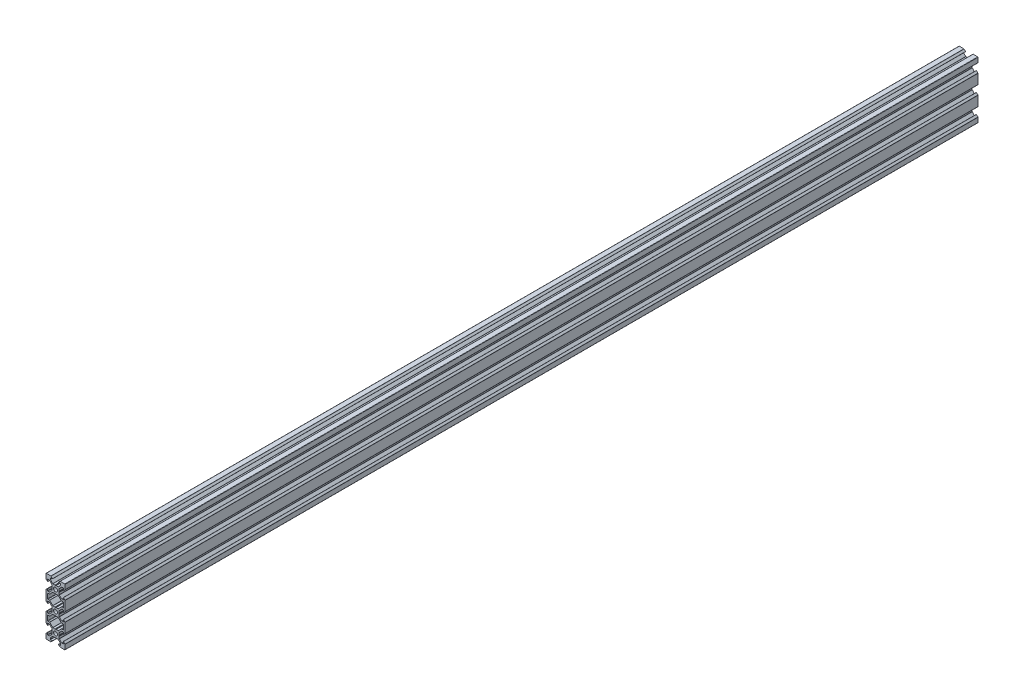
from build123d import *

# Parameters (mm, degrees)
BOSS_EXTRU_1_DEPTH = 960


with BuildPart() as part:
    # Esquisse1 → Boss.-Extru.1 (new body)
    with BuildSketch(Plane.XY):
        with BuildLine():
            Line((6.114160649, 19.573320158), (6.414160649, 20.0929354))
            Line((6.414160649, 20.0929354), (6.414160649, 22.289056089))
            ThreePointArc((6.414160649, 22.289056089), (6.43699679, 22.403861119), (6.502028615, 22.501188124))
            Line((6.502028615, 22.501188124), (8.985632512, 24.984792021))
            ThreePointArc((8.985632512, 24.984792021), (9.082959517, 25.049823846), (9.197764546, 25.072659986))
            Line((9.197764546, 25.072659986), (10.413500478, 25.072659986))
            ThreePointArc((10.413500478, 25.072659986), (10.625632512, 24.984792021), (10.713500478, 24.772659986))
            Line((10.713500478, 24.772659986), (10.713500478, 22.773320158))
            ThreePointArc((10.713500478, 22.773320158), (10.775232134, 22.680932205), (10.884211156, 22.70260948))
            Line((10.884211156, 22.70260948), (12.425632512, 24.244030836))
            ThreePointArc((12.425632512, 24.244030836), (12.490664337, 24.341357841), (12.513500478, 24.456162871))
            Line((12.513500478, 24.456162871), (12.513500478, 29.273320158))
            ThreePointArc((12.513500478, 29.273320158), (12.425632512, 29.485452192), (12.213500478, 29.573320158))
            Line((12.213500478, 29.573320158), (7.39634319, 29.573320158))
            ThreePointArc((7.39634319, 29.573320158), (7.28153816, 29.550484018), (7.184211156, 29.485452192))
            Line((7.184211156, 29.485452192), (5.642789799, 27.944030836))
            ThreePointArc((5.642789799, 27.944030836), (5.621112524, 27.835051815), (5.713500478, 27.773320158))
            Line((5.713500478, 27.773320158), (7.712840306, 27.773320158))
            ThreePointArc((7.712840306, 27.773320158), (7.92497234, 27.685452192), (8.012840306, 27.473320158))
            Line((8.012840306, 27.473320158), (8.012840306, 26.257584227))
            ThreePointArc((8.012840306, 26.257584227), (7.990004166, 26.142779197), (7.92497234, 26.045452192))
            Line((7.92497234, 26.045452192), (5.441368443, 23.561848296))
            ThreePointArc((5.441368443, 23.561848296), (5.344041439, 23.49681647), (5.229236409, 23.47398033))
            Line((5.229236409, 23.47398033), (3.03311572, 23.47398033))
            Line((3.03311572, 23.47398033), (2.513500478, 23.17398033))
            Line((2.513500478, 23.17398033), (1.993885235, 23.47398033))
            Line((1.993885235, 23.47398033), (-0.202235454, 23.47398033))
            ThreePointArc((-0.202235454, 23.47398033), (-0.317040483, 23.49681647), (-0.414367488, 23.561848296))
            Line((-0.414367488, 23.561848296), (-2.897971385, 26.045452192))
            ThreePointArc((-2.897971385, 26.045452192), (-2.96300321, 26.142779197), (-2.985839351, 26.257584227))
            Line((-2.985839351, 26.257584227), (-2.985839351, 27.473320158))
            ThreePointArc((-2.985839351, 27.473320158), (-2.897971385, 27.685452192), (-2.685839351, 27.773320158))
            Line((-2.685839351, 27.773320158), (-0.686499522, 27.773320158))
            ThreePointArc((-0.686499522, 27.773320158), (-0.594111569, 27.835051815), (-0.615788844, 27.944030836))
            Line((-0.615788844, 27.944030836), (-2.157210201, 29.485452192))
            ThreePointArc((-2.157210201, 29.485452192), (-2.254537205, 29.550484018), (-2.369342235, 29.573320158))
            Line((-2.369342235, 29.573320158), (-7.186499522, 29.573320158))
            ThreePointArc((-7.186499522, 29.573320158), (-7.398631557, 29.485452192), (-7.486499522, 29.273320158))
            Line((-7.486499522, 29.273320158), (-7.486499522, 24.456162871))
            ThreePointArc((-7.486499522, 24.456162871), (-7.463663382, 24.341357841), (-7.398631557, 24.244030836))
            Line((-7.398631557, 24.244030836), (-5.857210201, 22.70260948))
            ThreePointArc((-5.857210201, 22.70260948), (-5.748231179, 22.680932205), (-5.686499522, 22.773320158))
            Line((-5.686499522, 22.773320158), (-5.686499522, 24.772659986))
            ThreePointArc((-5.686499522, 24.772659986), (-5.598631557, 24.984792021), (-5.386499522, 25.072659986))
            Line((-5.386499522, 25.072659986), (-4.170763591, 25.072659986))
            ThreePointArc((-4.170763591, 25.072659986), (-4.055958561, 25.049823846), (-3.958631557, 24.984792021))
            Line((-3.958631557, 24.984792021), (-1.47502766, 22.501188124))
            ThreePointArc((-1.47502766, 22.501188124), (-1.409995834, 22.403861119), (-1.387159694, 22.289056089))
            Line((-1.387159694, 22.289056089), (-1.387159694, 20.0929354))
            Line((-1.387159694, 20.0929354), (-1.087159694, 19.573320158))
            Line((-1.087159694, 19.573320158), (-1.387159694, 19.053704916))
            Line((-1.387159694, 19.053704916), (-1.387159694, 16.857584227))
            ThreePointArc((-1.387159694, 16.857584227), (-1.409995834, 16.742779197), (-1.47502766, 16.645452192))
            Line((-1.47502766, 16.645452192), (-3.958631557, 14.161848296))
            ThreePointArc((-3.958631557, 14.161848296), (-4.055958561, 14.09681647), (-4.170763591, 14.07398033))
            Line((-4.170763591, 14.07398033), (-5.386499522, 14.07398033))
            ThreePointArc((-5.386499522, 14.07398033), (-5.598631557, 14.161848296), (-5.686499522, 14.37398033))
            Line((-5.686499522, 14.37398033), (-5.686499522, 16.373320158))
            ThreePointArc((-5.686499522, 16.373320158), (-5.748231179, 16.465708111), (-5.857210201, 16.444030836))
            Line((-5.857210201, 16.444030836), (-7.398631557, 14.90260948))
            ThreePointArc((-7.398631557, 14.90260948), (-7.463663382, 14.805282475), (-7.486499522, 14.690477446))
            Line((-7.486499522, 14.690477446), (-7.486499522, 9.573320158))
            Line((-7.486499522, 9.573320158), (-7.486499522, 4.456162871))
            ThreePointArc((-7.486499522, 4.456162871), (-7.463663382, 4.341357841), (-7.398631557, 4.244030836))
            Line((-7.398631557, 4.244030836), (-5.857210201, 2.70260948))
            ThreePointArc((-5.857210201, 2.70260948), (-5.748231179, 2.680932205), (-5.686499522, 2.773320158))
            Line((-5.686499522, 2.773320158), (-5.686499522, 4.772659986))
            ThreePointArc((-5.686499522, 4.772659986), (-5.598631557, 4.984792021), (-5.386499522, 5.072659986))
            Line((-5.386499522, 5.072659986), (-4.170763591, 5.072659986))
            ThreePointArc((-4.170763591, 5.072659986), (-4.055958561, 5.049823846), (-3.958631557, 4.984792021))
            Line((-3.958631557, 4.984792021), (-1.47502766, 2.501188124))
            ThreePointArc((-1.47502766, 2.501188124), (-1.409995834, 2.403861119), (-1.387159694, 2.289056089))
            Line((-1.387159694, 2.289056089), (-1.387159694, 0.0929354))
            Line((-1.387159694, 0.0929354), (-1.087159694, -0.426679842))
            Line((-1.087159694, -0.426679842), (-1.387159694, -0.946295084))
            Line((-1.387159694, -0.946295084), (-1.387159694, -3.142415773))
            ThreePointArc((-1.387159694, -3.142415773), (-1.409995834, -3.257220803), (-1.47502766, -3.354547808))
            Line((-1.47502766, -3.354547808), (-3.958631557, -5.838151704))
            ThreePointArc((-3.958631557, -5.838151704), (-4.055958561, -5.90318353), (-4.170763591, -5.92601967))
            Line((-4.170763591, -5.92601967), (-5.386499522, -5.92601967))
            ThreePointArc((-5.386499522, -5.92601967), (-5.598631557, -5.838151704), (-5.686499522, -5.62601967))
            Line((-5.686499522, -5.62601967), (-5.686499522, -3.626679842))
            ThreePointArc((-5.686499522, -3.626679842), (-5.748231179, -3.534291889), (-5.857210201, -3.555969164))
            Line((-5.857210201, -3.555969164), (-7.398631557, -5.09739052))
            ThreePointArc((-7.398631557, -5.09739052), (-7.463663382, -5.194717525), (-7.486499522, -5.309522554))
            Line((-7.486499522, -5.309522554), (-7.486499522, -10.426679842))
            Line((-7.486499522, -10.426679842), (-7.486499522, -15.543837129))
            ThreePointArc((-7.486499522, -15.543837129), (-7.463663382, -15.658642159), (-7.398631557, -15.755969164))
            Line((-7.398631557, -15.755969164), (-5.857210201, -17.29739052))
            ThreePointArc((-5.857210201, -17.29739052), (-5.748231179, -17.319067795), (-5.686499522, -17.226679842))
            Line((-5.686499522, -17.226679842), (-5.686499522, -15.227340014))
            ThreePointArc((-5.686499522, -15.227340014), (-5.598631557, -15.015207979), (-5.386499522, -14.927340014))
            Line((-5.386499522, -14.927340014), (-4.170763591, -14.927340014))
            ThreePointArc((-4.170763591, -14.927340014), (-4.055958561, -14.950176154), (-3.958631557, -15.015207979))
            Line((-3.958631557, -15.015207979), (-1.47502766, -17.498811876))
            ThreePointArc((-1.47502766, -17.498811876), (-1.409995834, -17.596138881), (-1.387159694, -17.710943911))
            Line((-1.387159694, -17.710943911), (-1.387159694, -19.9070646))
            Line((-1.387159694, -19.9070646), (-1.087159694, -20.426679842))
            Line((-1.087159694, -20.426679842), (-1.387159694, -20.946295084))
            Line((-1.387159694, -20.946295084), (-1.387159694, -23.142415773))
            ThreePointArc((-1.387159694, -23.142415773), (-1.409995834, -23.257220803), (-1.47502766, -23.354547808))
            Line((-1.47502766, -23.354547808), (-3.958631557, -25.838151704))
            ThreePointArc((-3.958631557, -25.838151704), (-4.055958561, -25.90318353), (-4.170763591, -25.92601967))
            Line((-4.170763591, -25.92601967), (-5.386499522, -25.92601967))
            ThreePointArc((-5.386499522, -25.92601967), (-5.598631557, -25.838151704), (-5.686499522, -25.62601967))
            Line((-5.686499522, -25.62601967), (-5.686499522, -23.626679842))
            ThreePointArc((-5.686499522, -23.626679842), (-5.748231179, -23.534291889), (-5.857210201, -23.555969164))
            Line((-5.857210201, -23.555969164), (-7.398631557, -25.09739052))
            ThreePointArc((-7.398631557, -25.09739052), (-7.463663382, -25.194717525), (-7.486499522, -25.309522554))
            Line((-7.486499522, -25.309522554), (-7.486499522, -30.126679842))
            ThreePointArc((-7.486499522, -30.126679842), (-7.398631557, -30.338811876), (-7.186499522, -30.426679842))
            Line((-7.186499522, -30.426679842), (-2.369342235, -30.426679842))
            ThreePointArc((-2.369342235, -30.426679842), (-2.254537205, -30.403843702), (-2.157210201, -30.338811876))
            Line((-2.157210201, -30.338811876), (-0.615788844, -28.79739052))
            ThreePointArc((-0.615788844, -28.79739052), (-0.594111569, -28.688411499), (-0.686499522, -28.626679842))
            Line((-0.686499522, -28.626679842), (-2.685839351, -28.626679842))
            ThreePointArc((-2.685839351, -28.626679842), (-2.897971385, -28.538811876), (-2.985839351, -28.326679842))
            Line((-2.985839351, -28.326679842), (-2.985839351, -27.110943911))
            ThreePointArc((-2.985839351, -27.110943911), (-2.96300321, -26.996138881), (-2.897971385, -26.898811876))
            Line((-2.897971385, -26.898811876), (-0.414367488, -24.415207979))
            ThreePointArc((-0.414367488, -24.415207979), (-0.317040483, -24.350176154), (-0.202235454, -24.327340014))
            Line((-0.202235454, -24.327340014), (1.993885235, -24.327340014))
            Line((1.993885235, -24.327340014), (2.513500478, -24.027340014))
            Line((2.513500478, -24.027340014), (3.03311572, -24.327340014))
            Line((3.03311572, -24.327340014), (5.229236409, -24.327340014))
            ThreePointArc((5.229236409, -24.327340014), (5.344041439, -24.350176154), (5.441368443, -24.415207979))
            Line((5.441368443, -24.415207979), (7.92497234, -26.898811876))
            ThreePointArc((7.92497234, -26.898811876), (7.990004166, -26.996138881), (8.012840306, -27.110943911))
            Line((8.012840306, -27.110943911), (8.012840306, -28.326679842))
            ThreePointArc((8.012840306, -28.326679842), (7.92497234, -28.538811876), (7.712840306, -28.626679842))
            Line((7.712840306, -28.626679842), (5.713500478, -28.626679842))
            ThreePointArc((5.713500478, -28.626679842), (5.621112524, -28.688411499), (5.642789799, -28.79739052))
            Line((5.642789799, -28.79739052), (7.184211156, -30.338811876))
            ThreePointArc((7.184211156, -30.338811876), (7.28153816, -30.403843702), (7.39634319, -30.426679842))
            Line((7.39634319, -30.426679842), (12.213500478, -30.426679842))
            ThreePointArc((12.213500478, -30.426679842), (12.425632512, -30.338811876), (12.513500478, -30.126679842))
            Line((12.513500478, -30.126679842), (12.513500478, -25.309522554))
            ThreePointArc((12.513500478, -25.309522554), (12.490664337, -25.194717525), (12.425632512, -25.09739052))
            Line((12.425632512, -25.09739052), (10.884211156, -23.555969164))
            ThreePointArc((10.884211156, -23.555969164), (10.775232134, -23.534291889), (10.713500478, -23.626679842))
            Line((10.713500478, -23.626679842), (10.713500478, -25.62601967))
            ThreePointArc((10.713500478, -25.62601967), (10.625632512, -25.838151704), (10.413500478, -25.92601967))
            Line((10.413500478, -25.92601967), (9.197764546, -25.92601967))
            ThreePointArc((9.197764546, -25.92601967), (9.082959517, -25.90318353), (8.985632512, -25.838151704))
            Line((8.985632512, -25.838151704), (6.502028615, -23.354547808))
            ThreePointArc((6.502028615, -23.354547808), (6.43699679, -23.257220803), (6.414160649, -23.142415773))
            Line((6.414160649, -23.142415773), (6.414160649, -20.946295084))
            Line((6.414160649, -20.946295084), (6.114160649, -20.426679842))
            Line((6.114160649, -20.426679842), (6.414160649, -19.9070646))
            Line((6.414160649, -19.9070646), (6.414160649, -17.710943911))
            ThreePointArc((6.414160649, -17.710943911), (6.43699679, -17.596138881), (6.502028615, -17.498811876))
            Line((6.502028615, -17.498811876), (8.985632512, -15.015207979))
            ThreePointArc((8.985632512, -15.015207979), (9.082959517, -14.950176154), (9.197764546, -14.927340014))
            Line((9.197764546, -14.927340014), (10.413500478, -14.927340014))
            ThreePointArc((10.413500478, -14.927340014), (10.625632512, -15.015207979), (10.713500478, -15.227340014))
            Line((10.713500478, -15.227340014), (10.713500478, -17.226679842))
            ThreePointArc((10.713500478, -17.226679842), (10.775232134, -17.319067795), (10.884211156, -17.29739052))
            Line((10.884211156, -17.29739052), (12.425632512, -15.755969164))
            ThreePointArc((12.425632512, -15.755969164), (12.490664337, -15.658642159), (12.513500478, -15.543837129))
            Line((12.513500478, -15.543837129), (12.513500478, -10.426679842))
            Line((12.513500478, -10.426679842), (12.513500478, -5.309522554))
            ThreePointArc((12.513500478, -5.309522554), (12.490664337, -5.194717525), (12.425632512, -5.09739052))
            Line((12.425632512, -5.09739052), (10.884211156, -3.555969164))
            ThreePointArc((10.884211156, -3.555969164), (10.775232134, -3.534291889), (10.713500478, -3.626679842))
            Line((10.713500478, -3.626679842), (10.713500478, -5.62601967))
            ThreePointArc((10.713500478, -5.62601967), (10.625632512, -5.838151704), (10.413500478, -5.92601967))
            Line((10.413500478, -5.92601967), (9.197764546, -5.92601967))
            ThreePointArc((9.197764546, -5.92601967), (9.082959517, -5.90318353), (8.985632512, -5.838151704))
            Line((8.985632512, -5.838151704), (6.502028615, -3.354547808))
            ThreePointArc((6.502028615, -3.354547808), (6.43699679, -3.257220803), (6.414160649, -3.142415773))
            Line((6.414160649, -3.142415773), (6.414160649, -0.946295084))
            Line((6.414160649, -0.946295084), (6.114160649, -0.426679842))
            Line((6.114160649, -0.426679842), (6.414160649, 0.0929354))
            Line((6.414160649, 0.0929354), (6.414160649, 2.289056089))
            ThreePointArc((6.414160649, 2.289056089), (6.43699679, 2.403861119), (6.502028615, 2.501188124))
            Line((6.502028615, 2.501188124), (8.985632512, 4.984792021))
            ThreePointArc((8.985632512, 4.984792021), (9.082959517, 5.049823846), (9.197764546, 5.072659986))
            Line((9.197764546, 5.072659986), (10.413500478, 5.072659986))
            ThreePointArc((10.413500478, 5.072659986), (10.625632512, 4.984792021), (10.713500478, 4.772659986))
            Line((10.713500478, 4.772659986), (10.713500478, 2.773320158))
            ThreePointArc((10.713500478, 2.773320158), (10.775232134, 2.680932205), (10.884211156, 2.70260948))
            Line((10.884211156, 2.70260948), (12.425632512, 4.244030836))
            ThreePointArc((12.425632512, 4.244030836), (12.490664337, 4.341357841), (12.513500478, 4.456162871))
            Line((12.513500478, 4.456162871), (12.513500478, 9.573320158))
            Line((12.513500478, 9.573320158), (12.513500478, 14.690477446))
            ThreePointArc((12.513500478, 14.690477446), (12.490664337, 14.805282475), (12.425632512, 14.90260948))
            Line((12.425632512, 14.90260948), (10.884211156, 16.444030836))
            ThreePointArc((10.884211156, 16.444030836), (10.775232134, 16.465708111), (10.713500478, 16.373320158))
            Line((10.713500478, 16.373320158), (10.713500478, 14.37398033))
            ThreePointArc((10.713500478, 14.37398033), (10.625632512, 14.161848296), (10.413500478, 14.07398033))
            Line((10.413500478, 14.07398033), (9.197764546, 14.07398033))
            ThreePointArc((9.197764546, 14.07398033), (9.082959517, 14.09681647), (8.985632512, 14.161848296))
            Line((8.985632512, 14.161848296), (6.502028615, 16.645452192))
            ThreePointArc((6.502028615, 16.645452192), (6.43699679, 16.742779197), (6.414160649, 16.857584227))
            Line((6.414160649, 16.857584227), (6.414160649, 19.053704916))
            Line((6.414160649, 19.053704916), (6.114160649, 19.573320158))
        make_face()
        with BuildLine():
            Line((10.413500478, -7.687340014), (8.837764546, -7.687340014))
            ThreePointArc((8.837764546, -7.687340014), (8.722959517, -7.664503873), (8.625632512, -7.599472048))
            Line((8.625632512, -7.599472048), (5.441368443, -4.415207979))
            ThreePointArc((5.441368443, -4.415207979), (5.344041439, -4.350176154), (5.229236409, -4.327340014))
            Line((5.229236409, -4.327340014), (3.03311572, -4.327340014))
            Line((3.03311572, -4.327340014), (2.513500478, -4.027340014))
            Line((2.513500478, -4.027340014), (1.993885235, -4.327340014))
            Line((1.993885235, -4.327340014), (-0.202235454, -4.327340014))
            ThreePointArc((-0.202235454, -4.327340014), (-0.317040483, -4.350176154), (-0.414367488, -4.415207979))
            Line((-0.414367488, -4.415207979), (-3.598631557, -7.599472048))
            ThreePointArc((-3.598631557, -7.599472048), (-3.695958561, -7.664503873), (-3.810763591, -7.687340014))
            Line((-3.810763591, -7.687340014), (-5.386499522, -7.687340014))
            ThreePointArc((-5.386499522, -7.687340014), (-5.598631557, -7.775207979), (-5.686499522, -7.987340014))
            Line((-5.686499522, -7.987340014), (-5.686499522, -10.426679842))
            Line((-5.686499522, -10.426679842), (-5.686499522, -12.86601967))
            ThreePointArc((-5.686499522, -12.86601967), (-5.598631557, -13.078151704), (-5.386499522, -13.16601967))
            Line((-5.386499522, -13.16601967), (-3.810763591, -13.16601967))
            ThreePointArc((-3.810763591, -13.16601967), (-3.695958561, -13.18885581), (-3.598631557, -13.253887636))
            Line((-3.598631557, -13.253887636), (-0.414367488, -16.438151704))
            ThreePointArc((-0.414367488, -16.438151704), (-0.317040483, -16.50318353), (-0.202235454, -16.52601967))
            Line((-0.202235454, -16.52601967), (1.993885235, -16.52601967))
            Line((1.993885235, -16.52601967), (2.513500478, -16.82601967))
            Line((2.513500478, -16.82601967), (3.03311572, -16.52601967))
            Line((3.03311572, -16.52601967), (5.229236409, -16.52601967))
            ThreePointArc((5.229236409, -16.52601967), (5.344041439, -16.50318353), (5.441368443, -16.438151704))
            Line((5.441368443, -16.438151704), (8.625632512, -13.253887636))
            ThreePointArc((8.625632512, -13.253887636), (8.722959517, -13.18885581), (8.837764546, -13.16601967))
            Line((8.837764546, -13.16601967), (10.413500478, -13.16601967))
            ThreePointArc((10.413500478, -13.16601967), (10.625632512, -13.078151704), (10.713500478, -12.86601967))
            Line((10.713500478, -12.86601967), (10.713500478, -10.426679842))
            Line((10.713500478, -10.426679842), (10.713500478, -7.987340014))
            ThreePointArc((10.713500478, -7.987340014), (10.625632512, -7.775207979), (10.413500478, -7.687340014))
        make_face(mode=Mode.SUBTRACT)
        with BuildLine():
            Line((10.413500478, 12.312659986), (8.837764546, 12.312659986))
            ThreePointArc((8.837764546, 12.312659986), (8.722959517, 12.335496127), (8.625632512, 12.400527952))
            Line((8.625632512, 12.400527952), (5.441368443, 15.584792021))
            ThreePointArc((5.441368443, 15.584792021), (5.344041439, 15.649823846), (5.229236409, 15.672659986))
            Line((5.229236409, 15.672659986), (3.03311572, 15.672659986))
            Line((3.03311572, 15.672659986), (2.513500478, 15.972659986))
            Line((2.513500478, 15.972659986), (1.993885235, 15.672659986))
            Line((1.993885235, 15.672659986), (-0.202235454, 15.672659986))
            ThreePointArc((-0.202235454, 15.672659986), (-0.317040483, 15.649823846), (-0.414367488, 15.584792021))
            Line((-0.414367488, 15.584792021), (-3.598631557, 12.400527952))
            ThreePointArc((-3.598631557, 12.400527952), (-3.695958561, 12.335496127), (-3.810763591, 12.312659986))
            Line((-3.810763591, 12.312659986), (-5.386499522, 12.312659986))
            ThreePointArc((-5.386499522, 12.312659986), (-5.598631557, 12.224792021), (-5.686499522, 12.012659986))
            Line((-5.686499522, 12.012659986), (-5.686499522, 9.573320158))
            Line((-5.686499522, 9.573320158), (-5.686499522, 7.13398033))
            ThreePointArc((-5.686499522, 7.13398033), (-5.598631557, 6.921848296), (-5.386499522, 6.83398033))
            Line((-5.386499522, 6.83398033), (-3.810763591, 6.83398033))
            ThreePointArc((-3.810763591, 6.83398033), (-3.695958561, 6.81114419), (-3.598631557, 6.746112364))
            Line((-3.598631557, 6.746112364), (-0.414367488, 3.561848296))
            ThreePointArc((-0.414367488, 3.561848296), (-0.317040483, 3.49681647), (-0.202235454, 3.47398033))
            Line((-0.202235454, 3.47398033), (1.993885235, 3.47398033))
            Line((1.993885235, 3.47398033), (2.513500478, 3.17398033))
            Line((2.513500478, 3.17398033), (3.03311572, 3.47398033))
            Line((3.03311572, 3.47398033), (5.229236409, 3.47398033))
            ThreePointArc((5.229236409, 3.47398033), (5.344041439, 3.49681647), (5.441368443, 3.561848296))
            Line((5.441368443, 3.561848296), (8.625632512, 6.746112364))
            ThreePointArc((8.625632512, 6.746112364), (8.722959517, 6.81114419), (8.837764546, 6.83398033))
            Line((8.837764546, 6.83398033), (10.413500478, 6.83398033))
            ThreePointArc((10.413500478, 6.83398033), (10.625632512, 6.921848296), (10.713500478, 7.13398033))
            Line((10.713500478, 7.13398033), (10.713500478, 9.573320158))
            Line((10.713500478, 9.573320158), (10.713500478, 12.012659986))
            ThreePointArc((10.713500478, 12.012659986), (10.625632512, 12.224792021), (10.413500478, 12.312659986))
        make_face(mode=Mode.SUBTRACT)
        with BuildLine():
            ThreePointArc((0.413500478, -20.426679842), (1.028576237, -21.911604082), (2.513500478, -22.526679842))
            ThreePointArc((2.513500478, -22.526679842), (3.998424718, -21.911604082), (4.613500478, -20.426679842))
            ThreePointArc((4.613500478, -20.426679842), (3.998424718, -18.941755601), (2.513500478, -18.326679842))
            ThreePointArc((2.513500478, -18.326679842), (1.028576237, -18.941755601), (0.413500478, -20.426679842))
        make_face(mode=Mode.SUBTRACT)
        with BuildLine():
            ThreePointArc((0.413500478, -0.426679842), (1.028576237, -1.911604082), (2.513500478, -2.526679842))
            ThreePointArc((2.513500478, -2.526679842), (3.998424718, -1.911604082), (4.613500478, -0.426679842))
            ThreePointArc((4.613500478, -0.426679842), (3.998424718, 1.058244399), (2.513500478, 1.673320158))
            ThreePointArc((2.513500478, 1.673320158), (1.028576237, 1.058244399), (0.413500478, -0.426679842))
        make_face(mode=Mode.SUBTRACT)
        with BuildLine():
            ThreePointArc((0.413500478, 19.573320158), (1.028576237, 18.088395918), (2.513500478, 17.473320158))
            ThreePointArc((2.513500478, 17.473320158), (3.998424718, 18.088395918), (4.613500478, 19.573320158))
            ThreePointArc((4.613500478, 19.573320158), (3.998424718, 21.058244399), (2.513500478, 21.673320158))
            ThreePointArc((2.513500478, 21.673320158), (1.028576237, 21.058244399), (0.413500478, 19.573320158))
        make_face(mode=Mode.SUBTRACT)
    extrude(amount=BOSS_EXTRU_1_DEPTH)


solid = part.part
